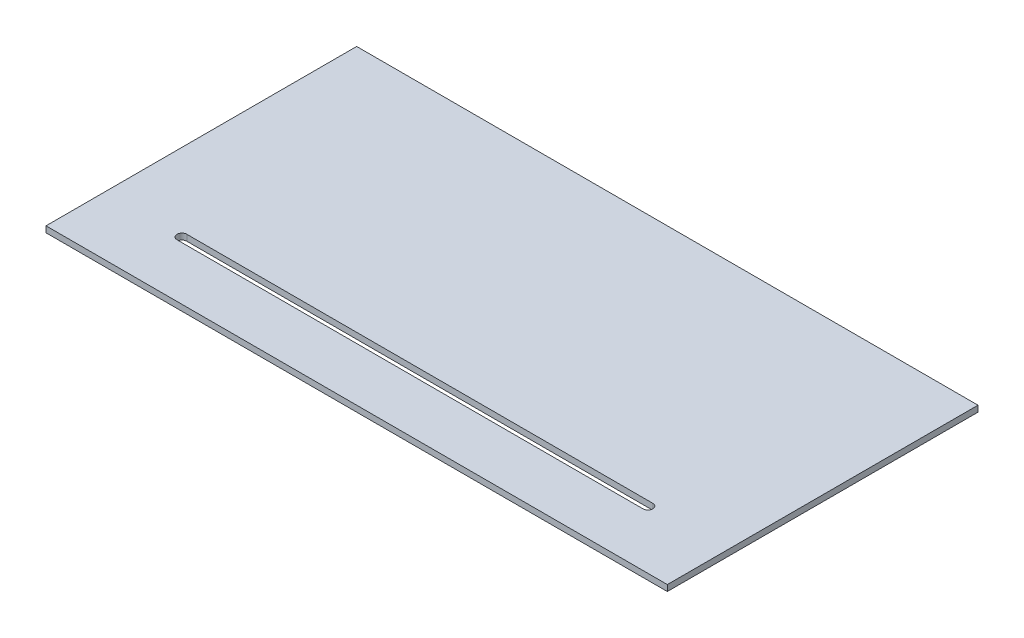
from build123d import *

# Parameters (mm, degrees)
SKETCH1_W           = 1219.2
SKETCH1_H           = 609.6
BOSS_EXTRUDE1_DEPTH = 11.90625
CUT_EXTRUDE1_DEPTH  = 12.90625


with BuildPart() as part:
    # Sketch1 → Boss-Extrude1 (new body)
    with BuildSketch(Plane(origin=(0, 0, 0), x_dir=(1, 0, 0), z_dir=(0, 1, 0))):
        Rectangle(SKETCH1_W, SKETCH1_H)
    extrude(amount=BOSS_EXTRUDE1_DEPTH)

    # Sketch2 → Cut-Extrude1 (cut, through all)
    with BuildSketch(Plane(origin=(0, 11.90625, 0), x_dir=(1, 0, 0), z_dir=(0, 1, 0))):
        with BuildLine():
            Line((-457.2, -180.975), (457.2, -180.975))
            ThreePointArc((457.2, -180.975), (466.725, -190.5), (457.2, -200.025))
            Line((457.2, -200.025), (-457.2, -200.025))
            ThreePointArc((-457.2, -200.025), (-466.725, -190.5), (-457.2, -180.975))
        make_face()
    extrude(amount=-CUT_EXTRUDE1_DEPTH, mode=Mode.SUBTRACT)


solid = part.part
